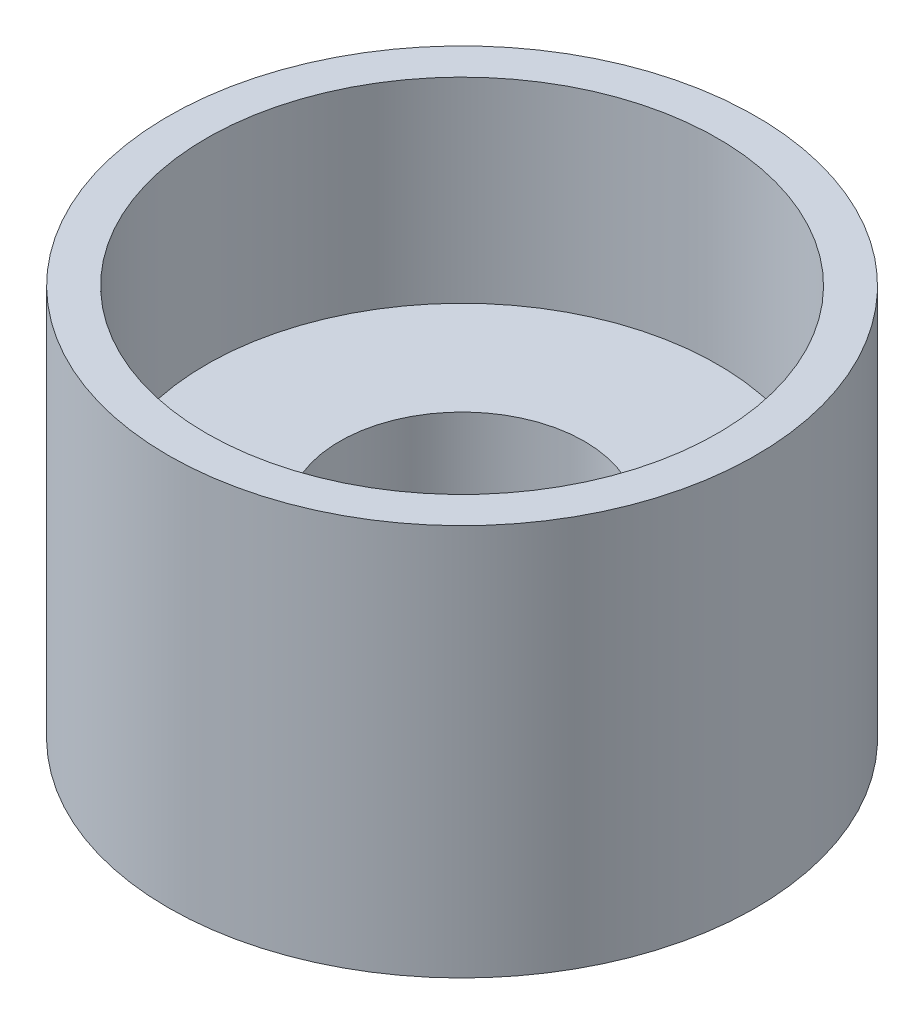
from build123d import *

# Parameters (mm, degrees)
SKETCH1_R           = 38.1
BOSS_EXTRUDE2_DEPTH = 50.8
SKETCH3_R           = 15.875
CUT_EXTRUDE2_DEPTH  = 47.752
SKETCH3_6_R         = 33.147
SKETCH3_6_R_2       = 15.875
CUT_EXTRUDE3_DEPTH  = 25.4
SKETCH4_R           = 9.525
CUT_EXTRUDE4_DEPTH  = 3.048


with BuildPart() as part:
    # Sketch1 → Boss-Extrude2 (new body)
    with BuildSketch(Plane(origin=(0, 0, 0), x_dir=(1, 0, 0), z_dir=(0, 1, 0))):
        Circle(SKETCH1_R)
    extrude(amount=BOSS_EXTRUDE2_DEPTH)

    # Sketch3 → Cut-Extrude2 (cut)
    with BuildSketch(Plane(origin=(0, 50.8, 0), x_dir=(1, 0, 0), z_dir=(0, 1, 0))):
        Circle(SKETCH3_R)
    extrude(amount=-CUT_EXTRUDE2_DEPTH, mode=Mode.SUBTRACT)

    # Sketch3_6 → Cut-Extrude3 (cut)
    with BuildSketch(Plane(origin=(0, 50.8, 0), x_dir=(1, 0, 0), z_dir=(0, 1, 0))):
        Circle(SKETCH3_6_R)
        Circle(SKETCH3_6_R_2, mode=Mode.SUBTRACT)
    extrude(amount=-CUT_EXTRUDE3_DEPTH, mode=Mode.SUBTRACT)

    # Sketch4 → Cut-Extrude4 (cut)
    with BuildSketch(Plane(origin=(0, 0, 0), x_dir=(-1, 0, 0), z_dir=(0, -1, 0))):
        Circle(SKETCH4_R)
    extrude(amount=-CUT_EXTRUDE4_DEPTH, mode=Mode.SUBTRACT)


solid = part.part
